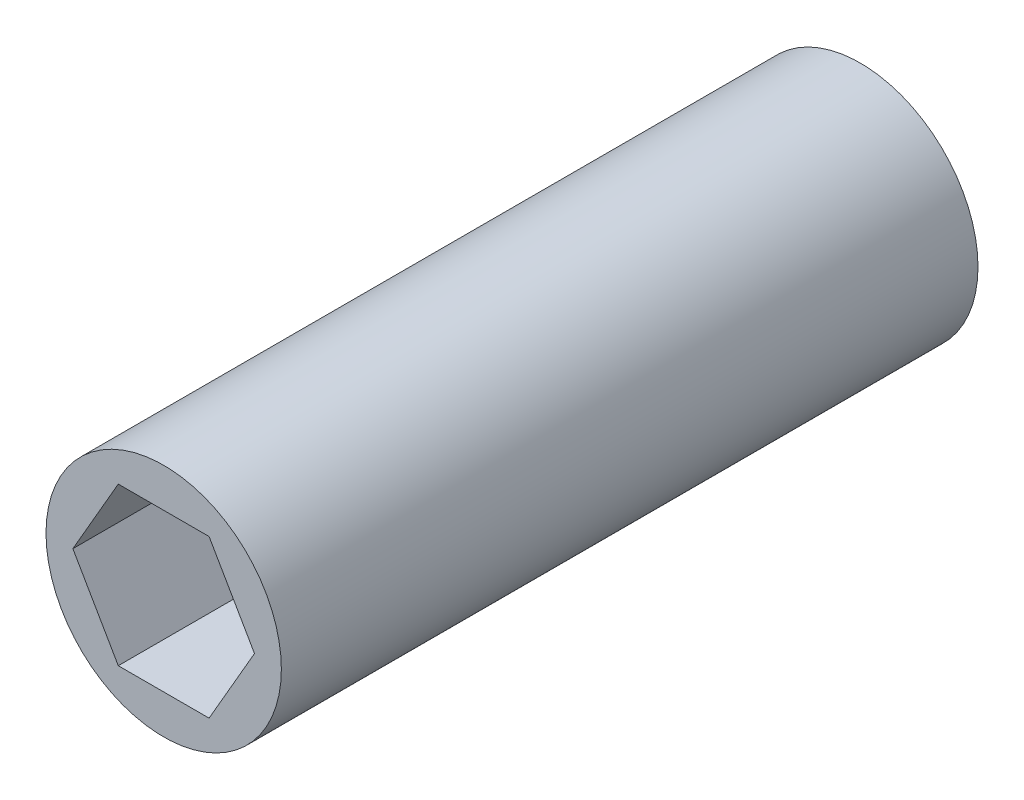
from build123d import *

# Parameters (mm, degrees)
SKETCH1_R           = 7.5
BOSS_EXTRUDE1_DEPTH = 22.2


with BuildPart() as part:
    # Sketch1 → Boss-Extrude1 (new, symmetric)
    with BuildSketch(Plane.XY):
        Circle(SKETCH1_R)
        Polygon((5.787936449, 0), (2.893968224, 5.0125), (-2.893968224, 5.0125), (-5.787936449, 0), (-2.893968224, -5.0125), (2.893968224, -5.0125), align=None, mode=Mode.SUBTRACT)
    extrude(amount=BOSS_EXTRUDE1_DEPTH, both=True)


solid = part.part
